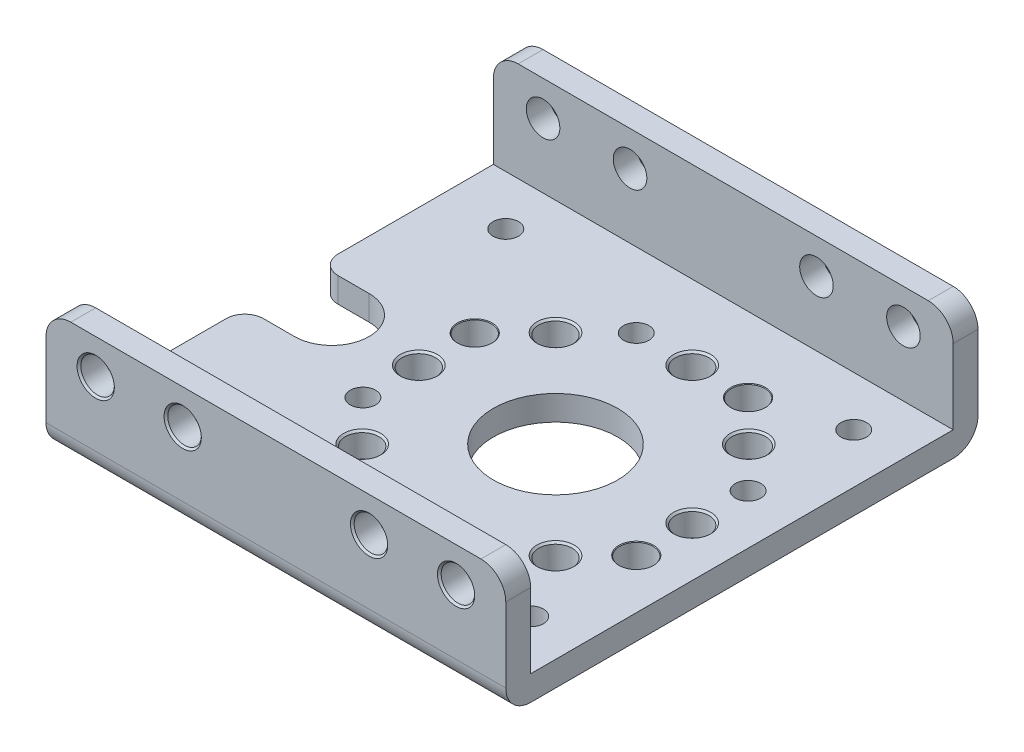
from build123d import *

# Parameters (mm, degrees)
SKETCH1_W                        = 37
SKETCH1_H                        = 38
BOSS_EXTRUDE1_DEPTH              = 10
SKETCH2_W                        = 34
SKETCH2_H                        = 8
CUT_EXTRUDE1_DEPTH               = 38
CUT_EXTRUDE2_DEPTH               = 3
F_2_05_2_05_DIAMETER_HOLE1_D     = 2.05
F_2_05_2_05_DIAMETER_HOLE1_DEPTH = 10
F_10_0_10_DIAMETER_HOLE1_D       = 10
F_10_0_10_DIAMETER_HOLE1_DEPTH   = 10
F_2_7_2_7_DIAMETER_HOLE1_D       = 2.7
F_2_7_2_7_DIAMETER_HOLE1_DEPTH   = 2
F_2_7_2_7_DIAMETER_HOLE2_D       = 2.7
F_2_7_2_7_DIAMETER_HOLE2_DEPTH   = 2
F_2_7_2_7_DIAMETER_HOLE3_D       = 2.7
F_2_7_2_7_DIAMETER_HOLE3_DEPTH   = 38
CHAMFER1_SIZE                    = 0.15
CHAMFER2_SIZE                    = 0.05
CHAMFER3_SIZE                    = 0.375
FILLET1_R                        = 1.5
FILLET2_R                        = 2


with BuildPart() as part:
    # Sketch1 → Boss-Extrude1 (new body)
    with BuildSketch(Plane(origin=(0, 10, 0), x_dir=(1, 0, 0), z_dir=(0, 1, 0))):
        with Locations((-3.5, 0)):
            Rectangle(SKETCH1_W, SKETCH1_H)
    extrude(amount=-BOSS_EXTRUDE1_DEPTH)

    # Sketch2 → Cut-Extrude1 (cut, through all)
    with BuildSketch(Plane(origin=(15, 0, 0), x_dir=(0, 0, -1), z_dir=(1, 0, 0))):
        with Locations((0, 6)):
            Rectangle(SKETCH2_W, SKETCH2_H)
    extrude(amount=-CUT_EXTRUDE1_DEPTH, mode=Mode.SUBTRACT)

    # Sketch3 → Cut-Extrude2 (cut, through all)
    with BuildSketch(Plane(origin=(0, 2, 0), x_dir=(-1, 0, 0), z_dir=(0, 1, 0))):
        with BuildLine():
            Line((22, -3), (22, 3))
            Line((22, 3), (18, 3))
            ThreePointArc((18, 3), (15, 0), (18, -3))
            Line((18, -3), (22, -3))
        make_face()
    extrude(amount=-CUT_EXTRUDE2_DEPTH, mode=Mode.SUBTRACT)

    # Ø2.05 (2.05) Diameter Hole1
    with Locations(Plane(origin=(0, 0, 0), x_dir=(-1, 0, 0), z_dir=(0, -1, 0))):
        with Locations((-11, 13), (-11, -13), (17, 13), (17, -13), (-11, 4.5), (-4.5, -11), (11, -4.5), (4.5, 11)):
            Hole(F_2_05_2_05_DIAMETER_HOLE1_D / 2, depth=F_2_05_2_05_DIAMETER_HOLE1_DEPTH)

    # Ø10.0 (10) Diameter Hole1
    with Locations(Plane(origin=(0, 0, 0), x_dir=(-1, 0, 0), z_dir=(0, -1, 0))):
        with Locations((0, 0)):
            Hole(F_10_0_10_DIAMETER_HOLE1_D / 2, depth=F_10_0_10_DIAMETER_HOLE1_DEPTH)

    # Ø2.7 (2.7) Diameter Hole1
    with Locations(Plane(origin=(0, 2, 0), x_dir=(1, 0, 0), z_dir=(0, 1, 0))):
        with Locations((11, 0), (7.778174593, 7.778174593), (0, 11), (-7.778174593, 7.778174593), (-11, 0), (-7.778174593, -7.778174593), (0, -11), (7.778174593, -7.778174593), (4.5, 11), (11, -4.5), (-4.5, -11), (-11, 4.5)):
            Hole(F_2_7_2_7_DIAMETER_HOLE1_D / 2, depth=F_2_7_2_7_DIAMETER_HOLE1_DEPTH)

    # Ø2.7 (2.7) Diameter Hole2
    with Locations(Plane.XY.offset(19)):
        with Locations((4, 7.2), (-18, 7.2), (11, 7.2), (-11, 7.2)):
            Hole(F_2_7_2_7_DIAMETER_HOLE2_D / 2, depth=F_2_7_2_7_DIAMETER_HOLE2_DEPTH)

    # Ø2.7 (2.7) Diameter Hole3
    with Locations(Plane(origin=(0, 0, -19), x_dir=(-1, 0, 0), z_dir=(0, 0, -1))):
        with Locations((-4, 7.2), (18, 7.2), (-11, 7.2), (11, 7.2)):
            Hole(F_2_7_2_7_DIAMETER_HOLE3_D / 2, depth=F_2_7_2_7_DIAMETER_HOLE3_DEPTH)

    # Chamfer1
    chamfer1_edges = [part.edges().sort_by_distance(p)[0] for p in [
        (9.128174593, 2, 7.778174593),
        (1.35, 2, 11),
        (-6.428174593, 2, 7.778174593),
        (-9.65, 2, 0),
        (-6.428174593, 2, -7.778174593),
        (1.35, 2, -11),
        (9.128174593, 2, -7.778174593),
        (12.35, 2, 0),
        (-9.65, 7.2, 19),
        (12.35, 7.2, 19),
        (-16.65, 7.2, 19),
        (5.35, 7.2, 19),
        (-12.35, 7.2, -19),
        (9.65, 7.2, -19),
        (-19.35, 7.2, -19),
        (2.65, 7.2, -19),
    ]]
    chamfer(chamfer1_edges, length=CHAMFER1_SIZE)

    # Chamfer2
    chamfer2_edges = [part.edges().sort_by_distance(p)[0] for p in [
        (-9.65, 2, -4.5),
        (-3.15, 2, 11),
        (12.35, 2, 4.5),
        (5.85, 2, -11),
    ]]
    chamfer(chamfer2_edges, length=CHAMFER2_SIZE)

    # Chamfer3
    chamfer3_edges = [part.edges().sort_by_distance(p)[0] for p in [
        (-5.525, 0, -11),
        (-12.025, 0, 4.5),
        (3.475, 0, 11),
        (9.975, 0, -4.5),
        (-18.025, 0, 13),
        (-18.025, 0, -13),
        (9.975, 0, 13),
        (9.975, 0, -13),
    ]]
    chamfer(chamfer3_edges, length=CHAMFER3_SIZE)

    # Fillet1
    fillet1_edges = [part.edges().sort_by_distance(p)[0] for p in [
        (-22, 1, -3),
        (-22, 1, 3),
    ]]
    fillet(fillet1_edges, radius=FILLET1_R)

    # Fillet2
    fillet2_edges = [part.edges().sort_by_distance(p)[0] for p in [
        (-3.5, 0, -19),
        (-22, 10, 18),
        (15, 10, -18),
        (15, 10, 18),
        (-22, 10, -18),
        (-3.5, 0, 19),
    ]]
    fillet(fillet2_edges, radius=FILLET2_R)


solid = part.part
